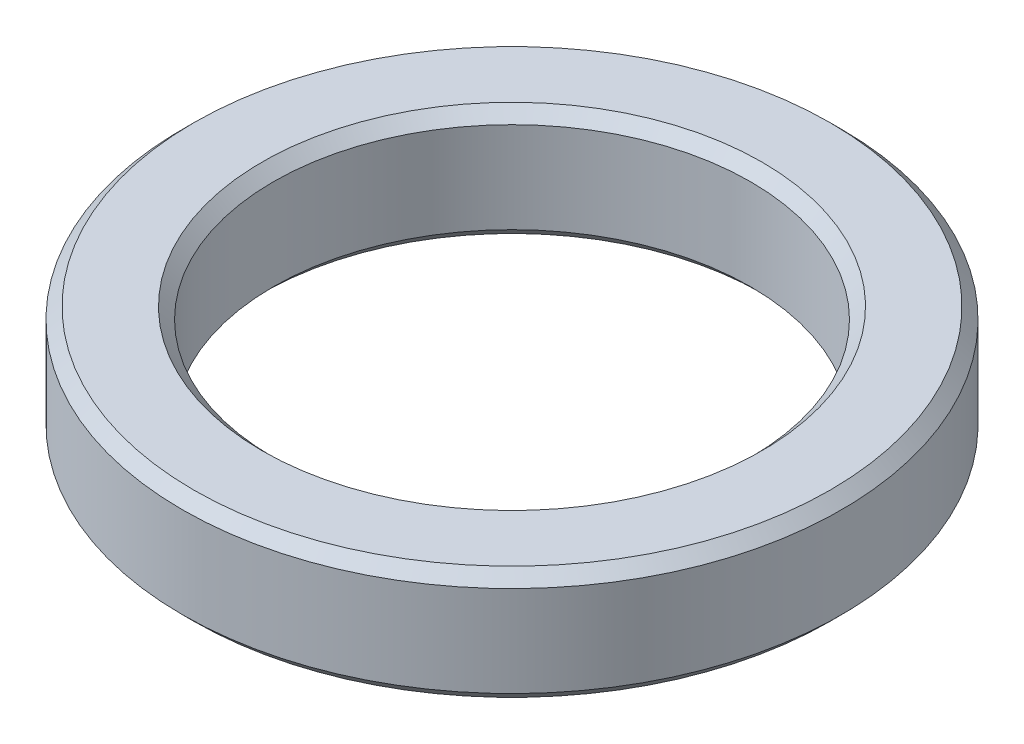
from build123d import *

# Parameters (mm, degrees)
SKETCH_2_R      = 14.5
SKETCH_2_R_2    = 10.5
EXTRUDE_1_DEPTH = 5
CHAMFER_1_SIZE  = 0.5


with BuildPart() as part:
    # 草图2 → 凸台-拉伸1 (new body)
    with BuildSketch(Plane(origin=(0, 0, 0), x_dir=(1, 0, 0), z_dir=(0, 1, 0))):
        Circle(SKETCH_2_R)
        Circle(SKETCH_2_R_2, mode=Mode.SUBTRACT)
    extrude(amount=EXTRUDE_1_DEPTH)

    # 倒角1
    chamfer_1_edges = [part.edges().sort_by_distance(p)[0] for p in [
        (-14.5, 0, 0),
        (-14.5, 5, 0),
        (-10.5, 0, 0),
        (-10.5, 5, 0),
    ]]
    chamfer(chamfer_1_edges, length=CHAMFER_1_SIZE)


solid = part.part
